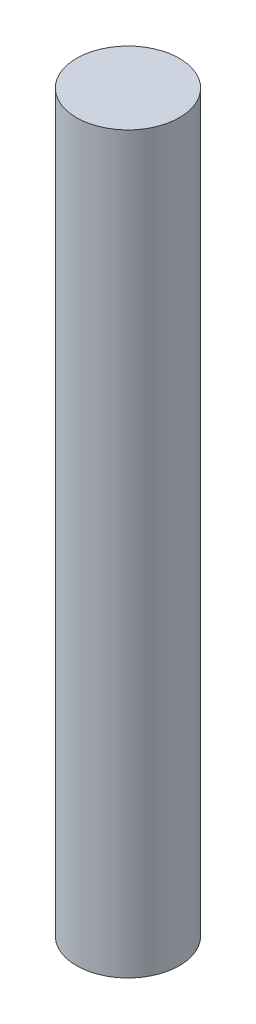
from build123d import *

# Parameters (mm, degrees)
SKETCH1_R           = 3.5
BOSS_EXTRUDE1_DEPTH = 50


with BuildPart() as part:
    # Sketch1 → Boss-Extrude1 (new body)
    with BuildSketch(Plane(origin=(0, 0, 0), x_dir=(1, 0, 0), z_dir=(0, 1, 0))):
        with Locations((-56.840181938, 24.108077167)):
            Circle(SKETCH1_R)
    extrude(amount=BOSS_EXTRUDE1_DEPTH)


solid = part.part
